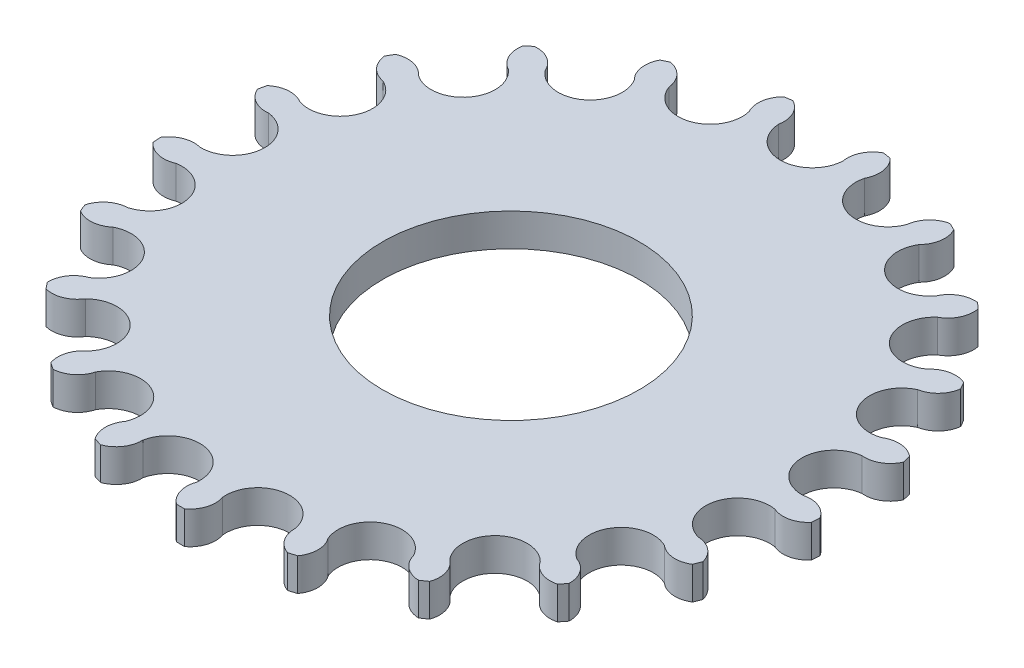
from build123d import *

# Parameters (mm, degrees)
SKETCH1_R               = 3
BOSS_EXTRUDE1_DEPTH     = 2.55
SKETCH2_R               = 10
CUT_EXTRUDE1_DEPTH      = 4
CUT_EXTRUDE1_DEPTH_BACK = 4


with BuildPart() as part:
    # Sketch1 → Boss-Extrude1 (new body)
    with BuildSketch(Plane(origin=(0, 0, 0), x_dir=(1, 0, 0), z_dir=(0, 1, 0))):
        with BuildLine():
            ThreePointArc((-2.496460827, 23.367021277), (0, 21), (2.496460827, 23.367021277))
            ThreePointArc((2.496460827, 23.367021277), (2.658416444, 24.60643544), (3.524555237, 25.507646116))
            ThreePointArc((3.524555237, 25.507646116), (3.837838354, 25.462393775), (4.150541543, 25.413293862))
            ThreePointArc((4.150541543, 25.413293862), (4.712563709, 24.296822557), (4.502000355, 23.064734831))
            ThreePointArc((4.502000355, 23.064734831), (6.189858663, 20.067028922), (9.273100509, 21.593045338))
            ThreePointArc((9.273100509, 21.593045338), (9.79318463, 22.729658551), (10.886479817, 23.335532074))
            ThreePointArc((10.886479817, 23.335532074), (11.172506282, 23.199948348), (11.456844492, 23.060858923))
            ThreePointArc((11.456844492, 23.060858923), (11.664811896, 21.828330364), (11.100439049, 20.713045477))
            ThreePointArc((11.100439049, 20.713045477), (11.829721219, 17.351014261), (15.225784516, 17.900432561))
            ThreePointArc((15.225784516, 17.900432561), (16.057785385, 18.833251753), (17.28109289, 19.089953602))
            ThreePointArc((17.28109289, 19.089953602), (17.514447998, 18.8760857), (17.745156531, 18.659365469))
            ThreePointArc((17.745156531, 18.659365469), (17.580590356, 17.420295227), (16.712555019, 16.520911135))
            ThreePointArc((16.712555019, 16.520911135), (16.418461132, 13.093285839), (19.825590752, 12.617287797))
            ThreePointArc((19.825590752, 12.617287797), (20.895581441, 13.263427887), (22.140205024, 13.148148977))
            ThreePointArc((22.140205024, 13.148148977), (22.300154147, 12.875), (22.456733538, 12.599905507))
            ThreePointArc((22.456733538, 12.599905507), (21.934256212, 11.464390411), (20.839687135, 10.860821338))
            ThreePointArc((20.839687135, 10.860821338), (19.548348722, 7.672161512), (22.663806246, 6.213041642))
            ThreePointArc((22.663806246, 6.213041642), (23.876713386, 6.515090249), (25.03206278, 6.038073615))
            ThreePointArc((25.03206278, 6.038073615), (25.104393739, 5.729914049), (25.172931221, 5.420888647))
            ThreePointArc((25.172931221, 5.420888647), (24.338967146, 4.489824196), (23.115121595, 4.235699903))
            ThreePointArc((23.115121595, 4.235699903), (20.941279741, 1.569331965), (23.488243097, -0.743260529))
            ThreePointArc((23.488243097, -0.743260529), (24.736294566, -0.812141749), (25.699711907, -1.608511084))
            ThreePointArc((25.699711907, -1.608511084), (25.677997777, -1.92429991), (25.652403496, -2.239797958))
            ThreePointArc((25.652403496, -2.239797958), (24.58105404, -2.883682602), (23.336676062, -2.765782057))
            ThreePointArc((23.336676062, -2.765782057), (20.473486156, -4.672939613), (22.225646472, -7.63352074))
            ThreePointArc((22.225646472, -7.63352074), (23.39794742, -8.067211389), (24.083828849, -9.112172516))
            ThreePointArc((24.083828849, -9.112172516), (23.969999028, -9.407531377), (23.852547146, -9.701468686))
            ThreePointArc((23.852547146, -9.701468686), (22.63900641, -10.000961546), (21.48466445, -9.521512143))
            ThreePointArc((21.48466445, -9.521512143), (18.186533479, -10.5), (18.988203623, -13.845509134))
            ThreePointArc((18.988203623, -13.845509134), (19.980589966, -14.605473895), (20.327991909, -15.80617743))
            ThreePointArc((20.327991909, -15.80617743), (20.132160674, -16.054862398), (19.933287307, -16.301121346))
            ThreePointArc((19.933287307, -16.301121346), (18.685383711, -16.229611167), (17.723646117, -15.431214091))
            ThreePointArc((17.723646117, -15.431214091), (14.283627493, -15.394089308), (14.063575553, -18.827263281))
            ThreePointArc((14.063575553, -18.827263281), (14.78786941, -19.845975949), (14.765923679, -21.095734116))
            ThreePointArc((14.765923679, -21.095734116), (14.505491495, -21.275648439), (14.242867415, -21.452347839))
            ThreePointArc((14.242867415, -21.452347839), (13.071482669, -21.016188615), (12.387804048, -19.969784948))
            ThreePointArc((12.387804048, -19.969784948), (9.111558521, -18.920346226), (7.889337079, -22.136132464))
            ThreePointArc((7.889337079, -22.136132464), (8.281181761, -23.323075949), (7.891838331, -24.510842249))
            ThreePointArc((7.891838331, -24.510842249), (7.589945741, -24.605999749), (7.286906249, -24.697439084))
            ThreePointArc((7.286906249, -24.697439084), (6.29612303, -23.935385475), (5.951251227, -22.733952776))
            ThreePointArc((5.951251227, -22.733952776), (3.12988759, -20.765447351), (1.014096383, -23.478109134))
            ThreePointArc((1.014096383, -23.478109134), (1.038674771, -24.727818298), (0.316528515, -25.748054484))
            ThreePointArc((0.316528515, -25.748054484), (0, -25.75), (-0.316528515, -25.748054484))
            ThreePointArc((-0.316528515, -25.748054484), (-1.038674771, -24.727818298), (-1.014096383, -23.478109134))
            ThreePointArc((-1.014096383, -23.478109134), (-3.12988759, -20.765447351), (-5.951251227, -22.733952776))
            ThreePointArc((-5.951251227, -22.733952776), (-6.29612303, -23.935385475), (-7.286906249, -24.697439084))
            ThreePointArc((-7.286906249, -24.697439084), (-7.589945741, -24.605999749), (-7.891838331, -24.510842249))
            ThreePointArc((-7.891838331, -24.510842249), (-8.281181761, -23.323075949), (-7.889337079, -22.136132464))
            ThreePointArc((-7.889337079, -22.136132464), (-9.111558521, -18.920346226), (-12.387804048, -19.969784948))
            ThreePointArc((-12.387804048, -19.969784948), (-13.071482669, -21.016188615), (-14.242867415, -21.452347839))
            ThreePointArc((-14.242867415, -21.452347839), (-14.505491495, -21.275648439), (-14.765923679, -21.095734116))
            ThreePointArc((-14.765923679, -21.095734116), (-14.78786941, -19.845975949), (-14.063575553, -18.827263281))
            ThreePointArc((-14.063575553, -18.827263281), (-14.283627493, -15.394089308), (-17.723646117, -15.431214091))
            ThreePointArc((-17.723646117, -15.431214091), (-18.685383711, -16.229611167), (-19.933287307, -16.301121346))
            ThreePointArc((-19.933287307, -16.301121346), (-20.132160674, -16.054862398), (-20.327991909, -15.80617743))
            ThreePointArc((-20.327991909, -15.80617743), (-19.980589966, -14.605473895), (-18.988203623, -13.845509134))
            ThreePointArc((-18.988203623, -13.845509134), (-18.186533479, -10.5), (-21.48466445, -9.521512143))
            ThreePointArc((-21.48466445, -9.521512143), (-22.63900641, -10.000961546), (-23.852547146, -9.701468686))
            ThreePointArc((-23.852547146, -9.701468686), (-23.969999028, -9.407531377), (-24.083828849, -9.112172516))
            ThreePointArc((-24.083828849, -9.112172516), (-23.39794742, -8.067211389), (-22.225646472, -7.63352074))
            ThreePointArc((-22.225646472, -7.63352074), (-20.473486156, -4.672939613), (-23.336676062, -2.765782057))
            ThreePointArc((-23.336676062, -2.765782057), (-24.58105404, -2.883682602), (-25.652403496, -2.239797958))
            ThreePointArc((-25.652403496, -2.239797958), (-25.677997777, -1.92429991), (-25.699711907, -1.608511084))
            ThreePointArc((-25.699711907, -1.608511084), (-24.736294566, -0.812141749), (-23.488243097, -0.743260529))
            ThreePointArc((-23.488243097, -0.743260529), (-20.941279741, 1.569331965), (-23.115121595, 4.235699903))
            ThreePointArc((-23.115121595, 4.235699903), (-24.338967146, 4.489824196), (-25.172931221, 5.420888647))
            ThreePointArc((-25.172931221, 5.420888647), (-25.104393739, 5.729914049), (-25.03206278, 6.038073615))
            ThreePointArc((-25.03206278, 6.038073615), (-23.876713386, 6.515090249), (-22.663806246, 6.213041642))
            ThreePointArc((-22.663806246, 6.213041642), (-19.548348722, 7.672161512), (-20.839687135, 10.860821338))
            ThreePointArc((-20.839687135, 10.860821338), (-21.934256212, 11.464390411), (-22.456733538, 12.599905507))
            ThreePointArc((-22.456733538, 12.599905507), (-22.300154147, 12.875), (-22.140205024, 13.148148977))
            ThreePointArc((-22.140205024, 13.148148977), (-20.895581441, 13.263427887), (-19.825590752, 12.617287797))
            ThreePointArc((-19.825590752, 12.617287797), (-16.418461132, 13.093285839), (-16.712555019, 16.520911135))
            ThreePointArc((-16.712555019, 16.520911135), (-17.580590356, 17.420295227), (-17.745156531, 18.659365469))
            ThreePointArc((-17.745156531, 18.659365469), (-17.514447998, 18.8760857), (-17.28109289, 19.089953602))
            ThreePointArc((-17.28109289, 19.089953602), (-16.057785385, 18.833251753), (-15.225784516, 17.900432561))
            ThreePointArc((-15.225784516, 17.900432561), (-11.829721219, 17.351014261), (-11.100439049, 20.713045477))
            ThreePointArc((-11.100439049, 20.713045477), (-11.664811896, 21.828330364), (-11.456844492, 23.060858923))
            ThreePointArc((-11.456844492, 23.060858923), (-11.172506282, 23.199948348), (-10.886479817, 23.335532074))
            ThreePointArc((-10.886479817, 23.335532074), (-9.79318463, 22.729658551), (-9.273100509, 21.593045338))
            ThreePointArc((-9.273100509, 21.593045338), (-6.189858663, 20.067028922), (-4.502000355, 23.064734831))
            ThreePointArc((-4.502000355, 23.064734831), (-4.712563709, 24.296822557), (-4.150541543, 25.413293862))
            ThreePointArc((-4.150541543, 25.413293862), (-3.837838354, 25.462393775), (-3.524555237, 25.507646116))
            ThreePointArc((-3.524555237, 25.507646116), (-2.658416444, 24.60643544), (-2.496460827, 23.367021277))
        make_face()
        with Locations((-6.5, 0)):
            Circle(SKETCH1_R, mode=Mode.SUBTRACT)
        with Locations((0, 7)):
            Circle(SKETCH1_R, mode=Mode.SUBTRACT)
        with Locations((7, 0)):
            Circle(SKETCH1_R, mode=Mode.SUBTRACT)
        with Locations((0, -7)):
            Circle(SKETCH1_R, mode=Mode.SUBTRACT)
    extrude(amount=BOSS_EXTRUDE1_DEPTH)

    # Sketch2 → Cut-Extrude1 (cut, two sides)
    with BuildSketch(Plane(origin=(0, 1.275, 0), x_dir=(1, 0, 0), z_dir=(0, 1, 0))) as cut_extrude1_sk:
        Circle(SKETCH2_R)
    extrude(amount=CUT_EXTRUDE1_DEPTH, mode=Mode.SUBTRACT)
    extrude(cut_extrude1_sk.sketch, amount=-CUT_EXTRUDE1_DEPTH_BACK, mode=Mode.SUBTRACT)


solid = part.part
